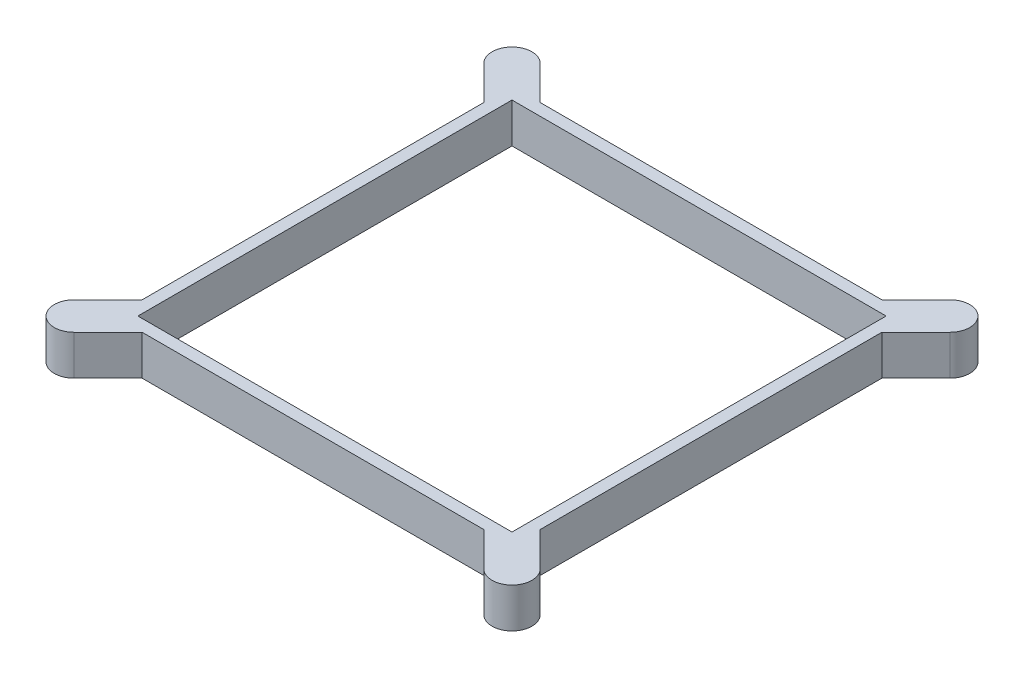
from build123d import *

# Parameters (mm, degrees)
SKETCH1_W               = 200
SKETCH1_H               = 200
BOSS_EXTRUDE1_DEPTH     = 20
BOSS_EXTRUDE2_DEPTH     = 20
SKETCH2_4_R             = 3.7970867
CUT_EXTRUDE2_DEPTH      = 10
MIRROR4_COPY_1_DEPTH    = 20
MIRROR4_COPY_2_SKETCH_R = 3.7970867
MIRROR4_COPY_2_DEPTH    = 10
SKETCH3_W               = 188
SKETCH3_H               = 188
CUT_EXTRUDE1_DEPTH      = 21


with BuildPart() as part:
    # Sketch1 → Boss-Extrude1 (new body)
    with BuildSketch(Plane(origin=(0, 0, 0), x_dir=(1, 0, 0), z_dir=(0, 1, 0))):
        with Locations((100, 100)):
            Rectangle(SKETCH1_W, SKETCH1_H)
    extrude(amount=BOSS_EXTRUDE1_DEPTH)

    # Sketch2 → Boss-Extrude2 (add)
    with BuildSketch(Plane.XZ):
        with BuildLine():
            Line((-17.087625271, 2.945489647), (0, -14.142135624))
            Line((0, -14.142135624), (0, 0))
            Line((0, 0), (14.142135624, 0))
            Line((14.142135624, 0), (-2.945489647, 17.087625271))
            ThreePointArc((-2.945489647, 17.087625271), (-17.087625271, 17.087625271), (-17.087625271, 2.945489647))
        make_face()
    boss_extrude2 = extrude(amount=-BOSS_EXTRUDE2_DEPTH)

    # Sketch2_4 → Cut-Extrude2 (cut)
    with BuildSketch(Plane.XZ):
        with Locations((-10.016557459, 10.016557459)):
            Circle(SKETCH2_4_R)
        with Locations((-3.415367361, 3.415367361)):
            Circle(SKETCH2_4_R)
    cut_extrude2 = extrude(amount=-CUT_EXTRUDE2_DEPTH, mode=Mode.SUBTRACT)

    # Mirror3: Boss-Extrude2, Cut-Extrude2 across plane
    add(boss_extrude2.mirror(Plane(origin=(100, 0, 0), x_dir=(0, 0, 1), z_dir=(1, 0, 0))))
    add(cut_extrude2.mirror(Plane(origin=(100, 0, 0), x_dir=(0, 0, 1), z_dir=(1, 0, 0))), mode=Mode.SUBTRACT)

    # Mirror4: Boss-Extrude2, Cut-Extrude2 across plane
    add(boss_extrude2.mirror(Plane(origin=(0, 0, -100), x_dir=(1, 0, 0), z_dir=(0, 0, -1))))
    add(cut_extrude2.mirror(Plane(origin=(0, 0, -100), x_dir=(1, 0, 0), z_dir=(0, 0, -1))), mode=Mode.SUBTRACT)

    # Mirror4 copy 1 sketch → Mirror4 copy 1 (add)
    with BuildSketch(Plane(origin=(200, 0, -200), x_dir=(-1, 0, 0), z_dir=(0, -1, 0))):
        with BuildLine():
            Line((-17.087625271, 2.945489647), (0, -14.142135624))
            Line((0, -14.142135624), (0, 0))
            Line((0, 0), (14.142135624, 0))
            Line((14.142135624, 0), (-2.945489647, 17.087625271))
            ThreePointArc((-2.945489647, 17.087625271), (-17.087625271, 17.087625271), (-17.087625271, 2.945489647))
        make_face()
    extrude(amount=-MIRROR4_COPY_1_DEPTH)

    # Mirror4 copy 2 sketch → Mirror4 copy 2 (cut)
    with BuildSketch(Plane(origin=(200, 0, -200), x_dir=(-1, 0, 0), z_dir=(0, -1, 0))):
        with Locations((-10.016557459, 10.016557459)):
            Circle(MIRROR4_COPY_2_SKETCH_R)
        with Locations((-3.415367361, 3.415367361)):
            Circle(MIRROR4_COPY_2_SKETCH_R)
    extrude(amount=-MIRROR4_COPY_2_DEPTH, mode=Mode.SUBTRACT)

    # Sketch3 → Cut-Extrude1 (cut, through all)
    with BuildSketch(Plane.XZ):
        with Locations((100, -100)):
            Rectangle(SKETCH3_W, SKETCH3_H)
    extrude(amount=-CUT_EXTRUDE1_DEPTH, mode=Mode.SUBTRACT)


solid = part.part
